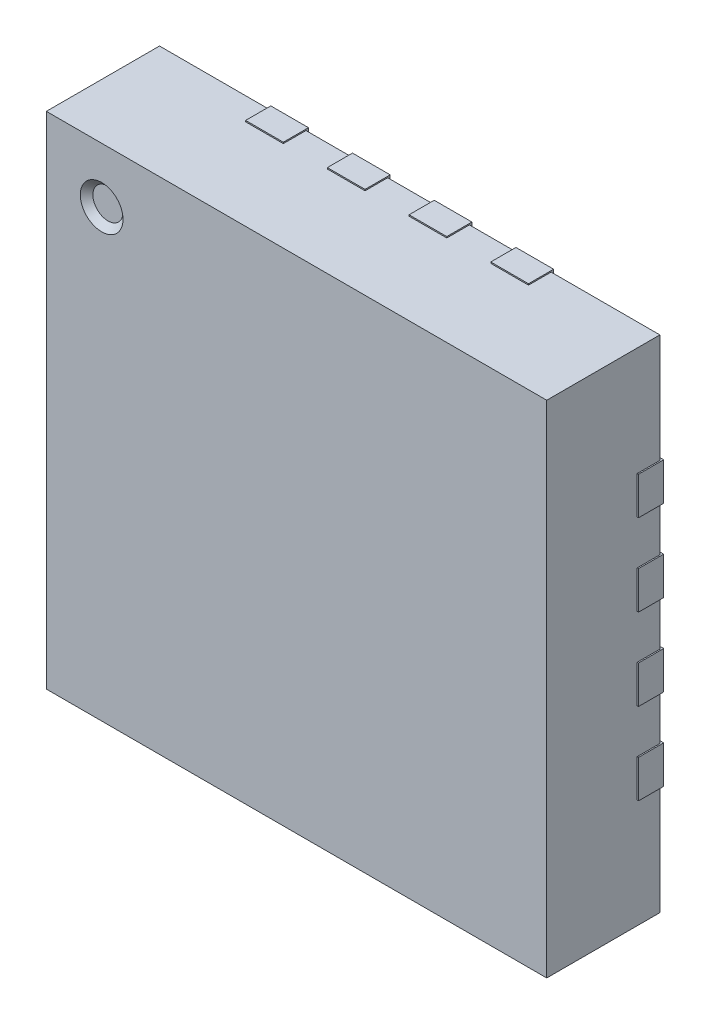
from build123d import *

# Parameters (mm, degrees)
EXTRUDE_START       = 0.02
SKETCH_1_W          = 3.98
SKETCH_1_H          = 3.98
EXTRUDE_1_DEPTH     = 0.9
SKETCH_2_R          = 0.17
CUT_EXTRUDE_2_DEPTH = 0.05
CUT_EXTRUDE_2_DRAFT = -45
SKETCH_3_W          = 0.4
SKETCH_3_H          = 0.3
SKETCH_3_W_2        = 0.3
SKETCH_3_H_2        = 0.4
EXTRUDE_3_DEPTH     = 0.2


with BuildPart() as part:
    # Эскиз1 → Вытянуть1 (new body)
    with BuildSketch(Plane.XY.offset(EXTRUDE_START)):
        Rectangle(SKETCH_1_W, SKETCH_1_H)
    extrude(amount=EXTRUDE_1_DEPTH)


with BuildPart() as cut_extrude_2_tool:
    # Эскиз2 → Вытянуть2 (with draft: the straight prism first)
    with BuildSketch(Plane.XY.offset(0.92)):
        with Locations((-1.55, 1.55)):
            Circle(SKETCH_2_R)
    extrude(amount=-CUT_EXTRUDE_2_DEPTH)
    # Вытянуть2: the draft: its side faces are tilted about the plane it starts from
    cut_extrude_2_sides = [cut_extrude_2_tool.faces().sort_by_distance(p)[0] for p in [
        (-1.72, 1.55, 0.895),
    ]]
    draft(cut_extrude_2_sides, Plane.XY.offset(0.92), CUT_EXTRUDE_2_DRAFT)


with BuildPart() as part_1:
    add(part.part)

    # Вытянуть2: cut by cut_extrude_2_tool
    add(cut_extrude_2_tool.part, mode=Mode.SUBTRACT)

    # Эскиз3 → Вытянуть3 (add)
    with BuildSketch(Plane.XY):
        with Locations((-1.8, -0.325)):
            Rectangle(SKETCH_3_W, SKETCH_3_H)
        with Locations((-1.8, -0.975)):
            Rectangle(SKETCH_3_W, SKETCH_3_H)
        with Locations((-1.8, 0.975)):
            Rectangle(SKETCH_3_W, SKETCH_3_H)
        with Locations((-1.8, 0.325)):
            Rectangle(SKETCH_3_W, SKETCH_3_H)
        with Locations((-0.325, 1.8)):
            Rectangle(SKETCH_3_W_2, SKETCH_3_H_2)
        with Locations((-0.975, 1.8)):
            Rectangle(SKETCH_3_W_2, SKETCH_3_H_2)
        with Locations((0.975, 1.8)):
            Rectangle(SKETCH_3_W_2, SKETCH_3_H_2)
        with Locations((0.325, 1.8)):
            Rectangle(SKETCH_3_W_2, SKETCH_3_H_2)
        with Locations((1.8, 0.325)):
            Rectangle(SKETCH_3_W, SKETCH_3_H)
        with Locations((1.8, 0.975)):
            Rectangle(SKETCH_3_W, SKETCH_3_H)
        with Locations((1.8, -0.975)):
            Rectangle(SKETCH_3_W, SKETCH_3_H)
        with Locations((1.8, -0.325)):
            Rectangle(SKETCH_3_W, SKETCH_3_H)
        with Locations((0.325, -1.8)):
            Rectangle(SKETCH_3_W_2, SKETCH_3_H_2)
        with Locations((0.975, -1.8)):
            Rectangle(SKETCH_3_W_2, SKETCH_3_H_2)
        with Locations((-0.975, -1.8)):
            Rectangle(SKETCH_3_W_2, SKETCH_3_H_2)
        with Locations((-0.325, -1.8)):
            Rectangle(SKETCH_3_W_2, SKETCH_3_H_2)
    extrude(amount=EXTRUDE_3_DEPTH)


solid = part_1.part
